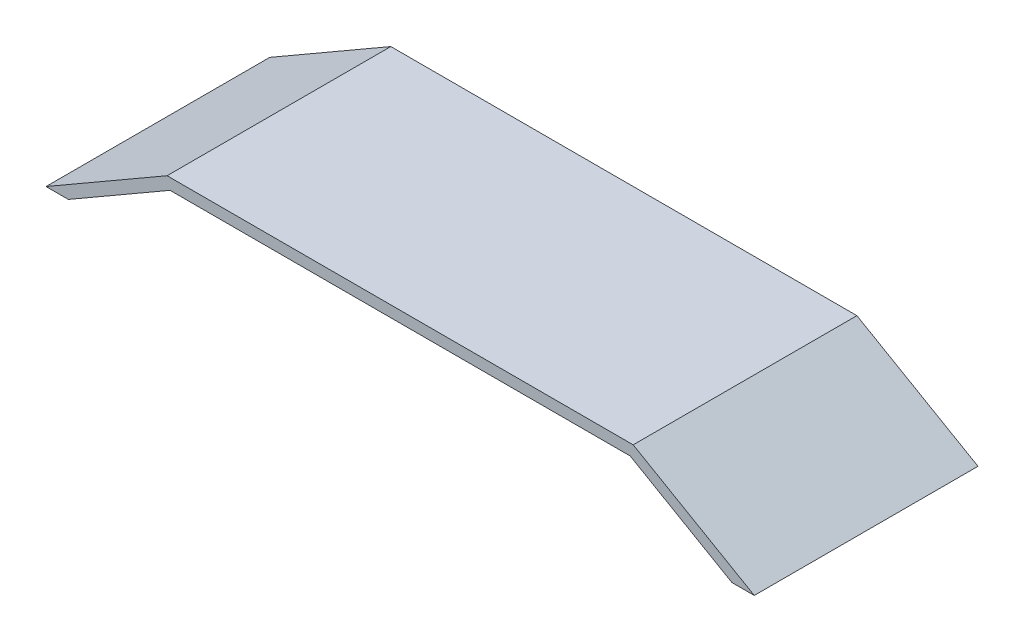
from build123d import *

# Parameters (mm, degrees)
EXTRUDE_1_DEPTH = 240


with BuildPart() as part:
    # 草图1 → 凸台-拉伸1 (new body)
    with BuildSketch(Plane.XY):
        Polygon((-250, 0), (250, 0), (379.903810568, -75), (355.903810568, -75), (246.784609691, -12), (-246.784609691, -12), (-355.903810568, -75), (-379.903810568, -75), align=None)
    extrude(amount=EXTRUDE_1_DEPTH)


solid = part.part
